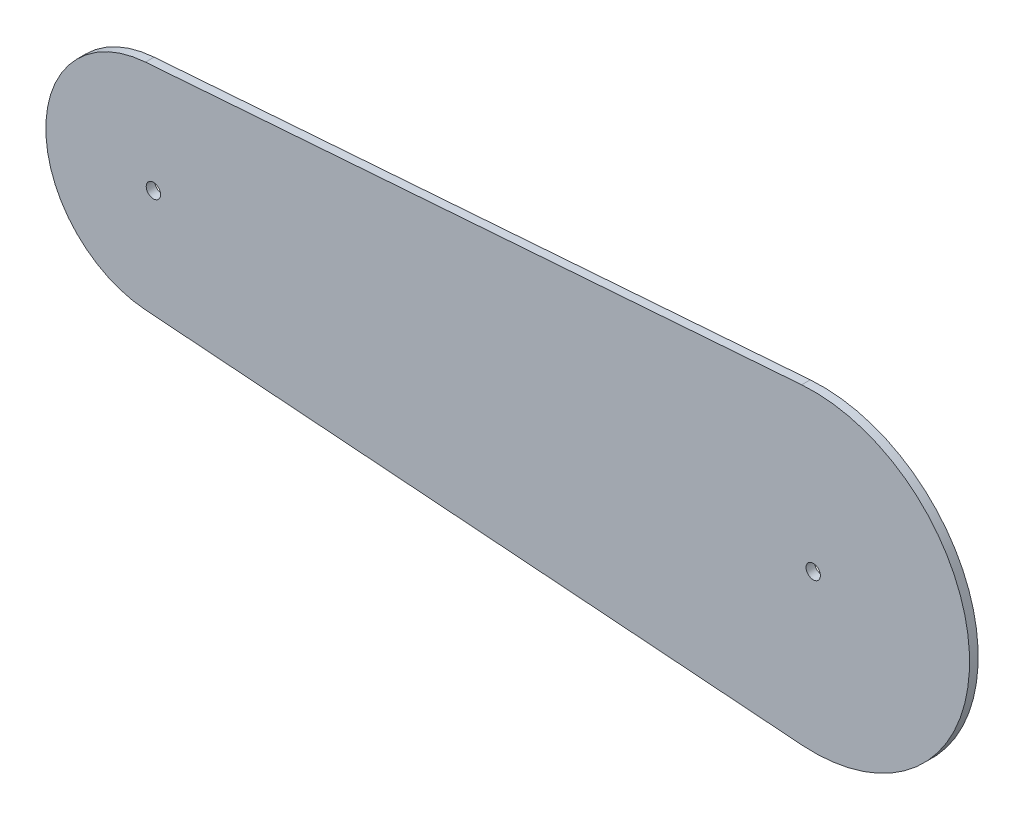
from build123d import *

# Parameters (mm, degrees)
SKETCH1_R           = 37.5
SKETCH1_R_2         = 2.5
SKETCH1_R_3         = 54.5
BOSS_EXTRUDE1_DEPTH = 3


with BuildPart() as part:
    # Sketch1 → Boss-Extrude1 (new body)
    with BuildSketch(Plane.XY):
        Circle(SKETCH1_R)
        Circle(SKETCH1_R_2, mode=Mode.SUBTRACT)
        with BuildLine():
            Line((225.97173913, 54.350925607), (-2.77173913, 37.397425877))
            ThreePointArc((-2.77173913, 37.397425877), (25.517736798, 27.478993953), (37.5, 0))
            ThreePointArc((37.5, 0), (25.517736798, -27.478993953), (-2.77173913, -37.397425877))
            Line((-2.77173913, -37.397425877), (225.97173913, -54.350925607))
            ThreePointArc((225.97173913, -54.350925607), (175.5, 0), (225.97173913, 54.350925607))
        make_face()
        with Locations((230, 0)):
            Circle(SKETCH1_R_3)
        with Locations((230, 0)):
            Circle(SKETCH1_R_2, mode=Mode.SUBTRACT)
    extrude(amount=BOSS_EXTRUDE1_DEPTH)


solid = part.part
